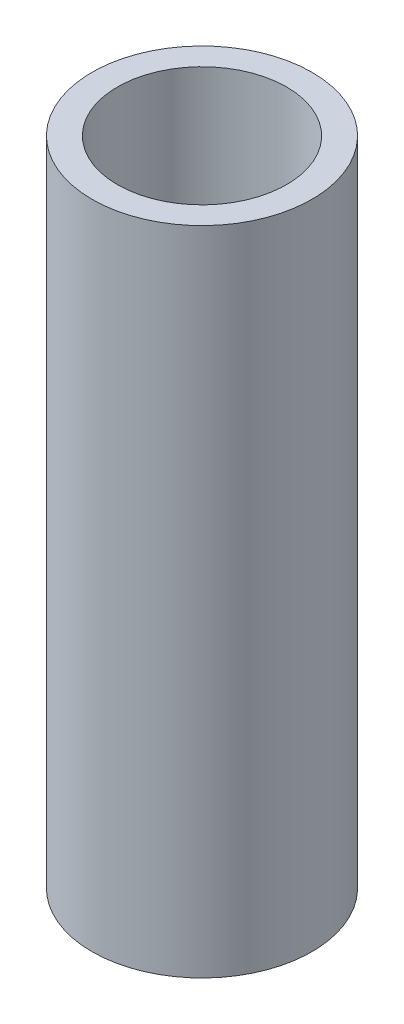
from build123d import *

# Parameters (mm, degrees)
SKETCH1_R           = 1.3
BOSS_EXTRUDE1_DEPTH = 7.7
SKETCH2_R           = 1
CUT_EXTRUDE1_DEPTH  = 7.2
CUT_EXTRUDE2_REACH  = 9.7
SKETCH3_R           = 0.5


with BuildPart() as part:
    # Sketch1 → Boss-Extrude1 (new body)
    with BuildSketch(Plane(origin=(0, 0, 0), x_dir=(1, 0, 0), z_dir=(0, 1, 0))):
        Circle(SKETCH1_R)
    extrude(amount=BOSS_EXTRUDE1_DEPTH)

    # Sketch2 → Cut-Extrude1 (cut)
    with BuildSketch(Plane(origin=(0, 7.7, 0), x_dir=(1, 0, 0), z_dir=(0, 1, 0))):
        Circle(SKETCH2_R)
    extrude(amount=-CUT_EXTRUDE1_DEPTH, mode=Mode.SUBTRACT)

    # Sketch3 → Cut-Extrude2 (cut, up to next)
    with BuildSketch(Plane.XZ, mode=Mode.PRIVATE) as cut_extrude2_sk1:
        Circle(SKETCH3_R)
    cut_extrude2_tool1 = extrude(cut_extrude2_sk1.sketch, amount=-CUT_EXTRUDE2_REACH, mode=Mode.PRIVATE) & part.part
    add(cut_extrude2_tool1.solids().sort_by_distance((0, 0, 0))[0], mode=Mode.SUBTRACT)


solid = part.part
